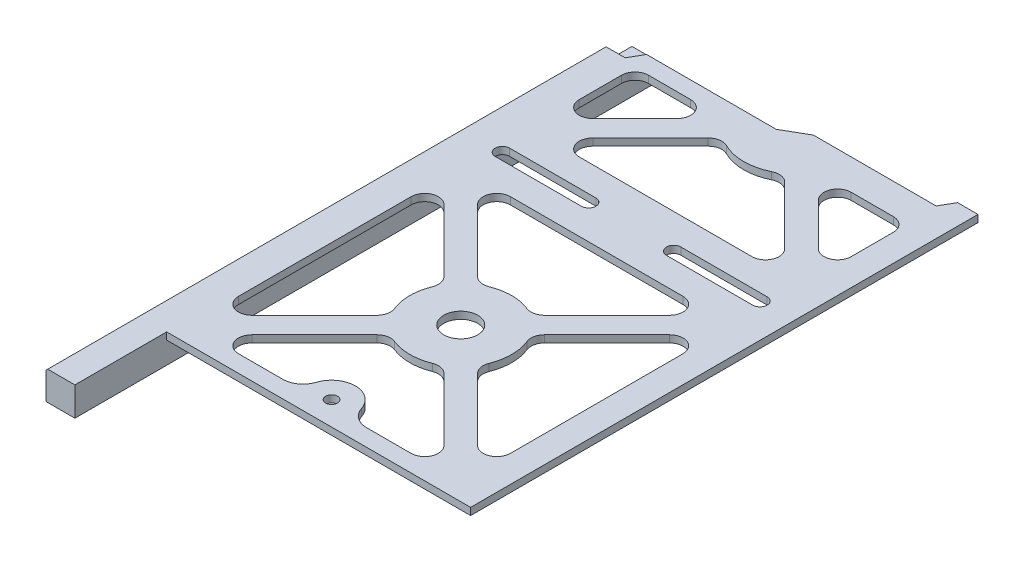
from build123d import *

# Parameters (mm, degrees)
SKETCH1_R           = 5
BOSS_EXTRUDE1_DEPTH = 2.1
SKETCH5_W           = 8.5
SKETCH5_H           = 170.25
BOSS_EXTRUDE3_DEPTH = 6.4
CUT_EXTRUDE2_DEPTH  = 2.1
SKETCH7_W           = 10
SKETCH7_H           = 2.5
BOSS_EXTRUDE4_DEPTH = 3
CHAMFER1_SIZE       = 0.5
SKETCH8_W           = 89.4
SKETCH8_H           = 20
CUT_EXTRUDE3_DEPTH  = 9.5
SKETCH9_R           = 1.75
BOSS_EXTRUDE8_DEPTH = 2.1


with BuildPart() as part:
    # Sketch1 → Boss-Extrude1 (new body)
    with BuildSketch(Plane(origin=(0, 0, 0), x_dir=(1, 0, 0), z_dir=(0, 1, 0))):
        Polygon((-48.95, -172.25), (-48.95, -8), (-42.85, -8), (-40.540598923, -4), (-2.414101615, -4), (4.514101615, 0), (40.640598923, 0), (42.95, 4), (48.95, 4), (48.95, -7.35), (48.95, -165.25), (-40.45, -165.25), (-40.45, -172.25), align=None)
        with Locations((1.05, -100.25)):
            Circle(SKETCH1_R, mode=Mode.SUBTRACT)
        with BuildLine():
            Line((-27.171825407, -133.421572875), (-8.819153161, -115.06890063))
            ThreePointArc((-8.819153161, -115.06890063), (-6.796732371, -113.979375), (-4.508467924, -114.182100859))
            ThreePointArc((-4.508467924, -114.182100859), (1.05, -115.25), (6.608467924, -114.182100859))
            ThreePointArc((6.608467924, -114.182100859), (8.896732371, -113.979375), (10.919153161, -115.06890063))
            Line((10.919153161, -115.06890063), (29.271825407, -133.421572875))
            ThreePointArc((29.271825407, -133.421572875), (30.138916412, -137.780733729), (26.443398282, -140.25))
            Line((26.443398282, -140.25), (-24.343398282, -140.25))
            ThreePointArc((-24.343398282, -140.25), (-28.038916412, -137.780733729), (-27.171825407, -133.421572875))
        make_face(mode=Mode.SUBTRACT)
        with BuildLine():
            Line((-34.95, -9), (-22.556601718, -9))
            ThreePointArc((-22.556601718, -9), (-18.861083588, -11.469266271), (-19.728174593, -15.828427125))
            Line((-19.728174593, -15.828427125), (-32.121572875, -28.221825407))
            ThreePointArc((-32.121572875, -28.221825407), (-36.480733729, -29.088916412), (-38.95, -25.393398282))
            Line((-38.95, -25.393398282), (-38.95, -13))
            ThreePointArc((-38.95, -13), (-37.778427125, -10.171572875), (-34.95, -9))
        make_face(mode=Mode.SUBTRACT)
        with BuildLine():
            Line((41.05, -13), (41.05, -25.393398282))
            ThreePointArc((41.05, -25.393398282), (38.580733729, -29.088916412), (34.221572875, -28.221825407))
            Line((34.221572875, -28.221825407), (21.828174593, -15.828427125))
            ThreePointArc((21.828174593, -15.828427125), (20.961083588, -11.469266271), (24.656601718, -9))
            Line((24.656601718, -9), (37.05, -9))
            ThreePointArc((37.05, -9), (39.878427125, -10.171572875), (41.05, -13))
        make_face(mode=Mode.SUBTRACT)
        with BuildLine():
            Line((-32.121572875, -128.471825407), (-13.76890063, -110.119153161))
            ThreePointArc((-13.76890063, -110.119153161), (-12.679375, -108.096732371), (-12.882100859, -105.808467924))
            ThreePointArc((-12.882100859, -105.808467924), (-13.95, -100.25), (-12.882100859, -94.691532076))
            ThreePointArc((-12.882100859, -94.691532076), (-12.679375, -92.403267629), (-13.76890063, -90.380846839))
            Line((-13.76890063, -90.380846839), (-32.121572875, -72.028174593))
            ThreePointArc((-32.121572875, -72.028174593), (-36.480733729, -71.161083588), (-38.95, -74.856601718))
            Line((-38.95, -74.856601718), (-38.95, -125.643398282))
            ThreePointArc((-38.95, -125.643398282), (-36.480733729, -129.338916412), (-32.121572875, -128.471825407))
        make_face(mode=Mode.SUBTRACT)
        with BuildLine():
            Line((34.221572875, -128.471825407), (15.86890063, -110.119153161))
            ThreePointArc((15.86890063, -110.119153161), (14.779375, -108.096732371), (14.982100859, -105.808467924))
            ThreePointArc((14.982100859, -105.808467924), (16.05, -100.25), (14.982100859, -94.691532076))
            ThreePointArc((14.982100859, -94.691532076), (14.779375, -92.403267629), (15.86890063, -90.380846839))
            Line((15.86890063, -90.380846839), (34.221572875, -72.028174593))
            ThreePointArc((34.221572875, -72.028174593), (38.580733729, -71.161083588), (41.05, -74.856601718))
            Line((41.05, -74.856601718), (41.05, -125.643398282))
            ThreePointArc((41.05, -125.643398282), (38.580733729, -129.338916412), (34.221572875, -128.471825407))
        make_face(mode=Mode.SUBTRACT)
        with BuildLine():
            Line((10.919153161, -85.43109937), (29.271825407, -67.078427125))
            ThreePointArc((29.271825407, -67.078427125), (30.138916412, -62.719266271), (26.443398282, -60.25))
            Line((26.443398282, -60.25), (-24.343398282, -60.25))
            ThreePointArc((-24.343398282, -60.25), (-28.038916412, -62.719266271), (-27.171825407, -67.078427125))
            Line((-27.171825407, -67.078427125), (-8.819153161, -85.43109937))
            ThreePointArc((-8.819153161, -85.43109937), (-6.796732371, -86.520625), (-4.508467924, -86.317899141))
            ThreePointArc((-4.508467924, -86.317899141), (1.05, -85.25), (6.608467924, -86.317899141))
            ThreePointArc((6.608467924, -86.317899141), (8.896732371, -86.520625), (10.919153161, -85.43109937))
        make_face(mode=Mode.SUBTRACT)
        with BuildLine():
            Line((-27.171825407, -33.171572875), (-10.202325554, -16.202073022))
            ThreePointArc((-10.202325554, -16.202073022), (-8.02311566, -15.083537139), (-5.600446128, -15.445131695))
            ThreePointArc((-5.600446128, -15.445131695), (1.05, -17), (7.700446128, -15.445131695))
            ThreePointArc((7.700446128, -15.445131695), (10.12311566, -15.083537139), (12.302325554, -16.202073022))
            Line((12.302325554, -16.202073022), (29.271825407, -33.171572875))
            ThreePointArc((29.271825407, -33.171572875), (30.138916412, -37.530733729), (26.443398282, -40))
            Line((26.443398282, -40), (-24.343398282, -40))
            ThreePointArc((-24.343398282, -40), (-28.038916412, -37.530733729), (-27.171825407, -33.171572875))
        make_face(mode=Mode.SUBTRACT)
        with BuildLine():
            Line((-36.825, -48), (-11.45, -48))
            ThreePointArc((-11.45, -48), (-9.325, -50.125), (-11.45, -52.25))
            Line((-11.45, -52.25), (-36.825, -52.25))
            ThreePointArc((-36.825, -52.25), (-38.95, -50.125), (-36.825, -48))
        make_face(mode=Mode.SUBTRACT)
        with BuildLine():
            Line((13.55, -48), (38.925, -48))
            ThreePointArc((38.925, -48), (41.05, -50.125), (38.925, -52.25))
            Line((38.925, -52.25), (13.55, -52.25))
            ThreePointArc((13.55, -52.25), (11.425, -50.125), (13.55, -48))
        make_face(mode=Mode.SUBTRACT)
    extrude(amount=BOSS_EXTRUDE1_DEPTH)

    # Sketch5 → Boss-Extrude3 (add)
    with BuildSketch(Plane.XZ):
        with Locations((-44.7, 87.125)):
            Rectangle(SKETCH5_W, SKETCH5_H)
    extrude(amount=BOSS_EXTRUDE3_DEPTH)

    # Sketch6 → Cut-Extrude2 (cut)
    with BuildSketch(Plane.ZY.offset(48.95)):
        Polygon((8, 0), (2, 0), (2, -6.4), (145.35, -6.4), (145.35, 0), (140.25, 0), align=None)
    extrude(amount=-CUT_EXTRUDE2_DEPTH, mode=Mode.SUBTRACT)

    # Sketch7 → Boss-Extrude4 (add)
    with BuildSketch(Plane.XZ):
        with Locations((21.05, 2)):
            Rectangle(SKETCH7_W, SKETCH7_H)
    extrude(amount=BOSS_EXTRUDE4_DEPTH)

    # Chamfer1
    chamfer1_edges = [part.edges().sort_by_distance(p)[0] for p in [
        (-48.95, 2.1, 90.125),
    ]]
    chamfer(chamfer1_edges, length=CHAMFER1_SIZE)

    # Sketch8 → Cut-Extrude3 (cut, through all)
    with BuildSketch(Plane(origin=(0, 2.1, 0), x_dir=(1, 0, 0), z_dir=(0, 1, 0))):
        with Locations((4.25, -155.25)):
            Rectangle(SKETCH8_W, SKETCH8_H)
    extrude(amount=-CUT_EXTRUDE3_DEPTH, mode=Mode.SUBTRACT)

    # Sketch9 → Boss-Extrude8 (add)
    with BuildSketch(Plane(origin=(0, 2.1, 0), x_dir=(1, 0, 0), z_dir=(0, 1, 0))):
        with BuildLine():
            Line((-11.319316877, -140.25), (13.419316877, -140.25))
            ThreePointArc((13.419316877, -140.25), (9.889226444, -139.10164524), (7.710401395, -136.096153846))
            ThreePointArc((7.710401395, -136.096153846), (1.05, -131.25), (-5.610401395, -136.096153846))
            ThreePointArc((-5.610401395, -136.096153846), (-7.789226444, -139.10164524), (-11.319316877, -140.25))
        make_face()
        with Locations((1.05, -138.25)):
            Circle(SKETCH9_R, mode=Mode.SUBTRACT)
    extrude(amount=-BOSS_EXTRUDE8_DEPTH)


solid = part.part
